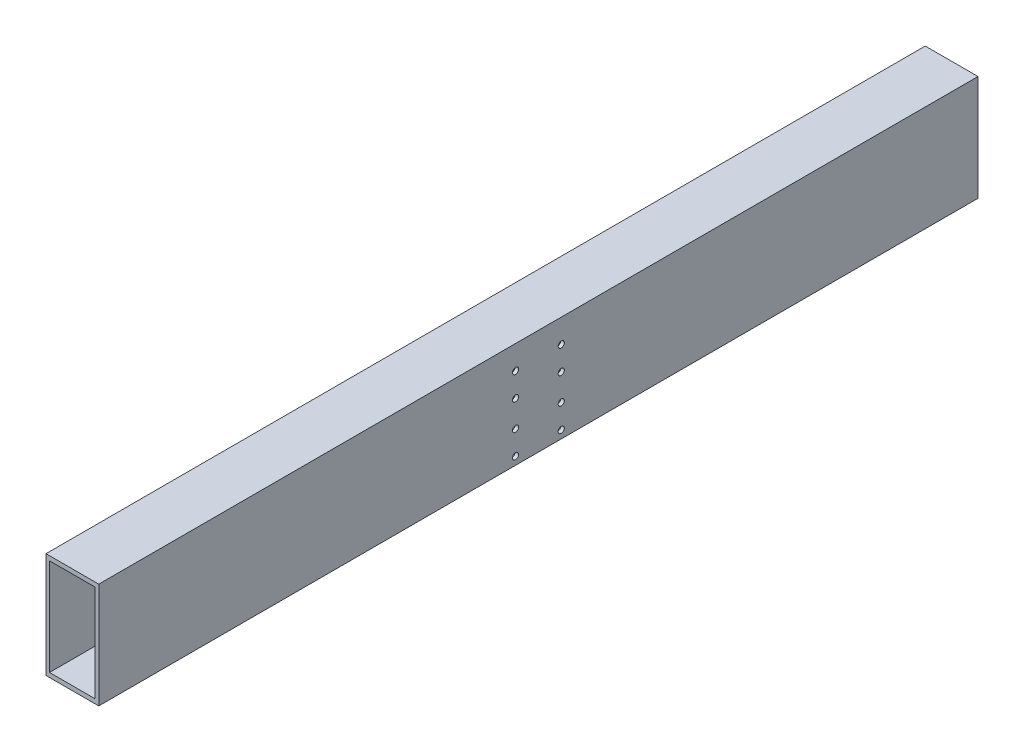
from build123d import *

# Parameters (mm, degrees)
SKETCH1_W                = 60
SKETCH1_H                = 120
SKETCH1_W_2              = 52
SKETCH1_H_2              = 110
F_7_0_7_DIAMETER_HOLE1_D = 7


with BuildPart() as part:
    # Sweep1: sweep along a curve in space
    with BuildLine() as sweep1_path:
        add(Edge.make_bspline(
            [(0, 0, -500), (0, 0, 500)],
            knots=[0, 0, 1, 1], degree=1))
    # Sketch1 → Sweep1 (sweep)
    with BuildSketch(Plane.XY):
        Rectangle(SKETCH1_W, SKETCH1_H)
        Rectangle(SKETCH1_W_2, SKETCH1_H_2, mode=Mode.SUBTRACT)
    sweep(path=sweep1_path.line)

    # Ø7.0 (7) Diameter Hole1 (through all)
    with Locations(Plane(origin=(30, 0, 0), x_dir=(0, 0, -1), z_dir=(1, 0, 0))):
        with Locations((26, 33), (26, 6), (26, -24), (26, -51)):
            f_7_0_7_diameter_hole1 = Hole(F_7_0_7_DIAMETER_HOLE1_D / 2)

    # Mirror1: Ø7.0 (7) Diameter Hole1 across plane
    add(f_7_0_7_diameter_hole1.mirror(Plane.XY), mode=Mode.SUBTRACT)


solid = part.part
